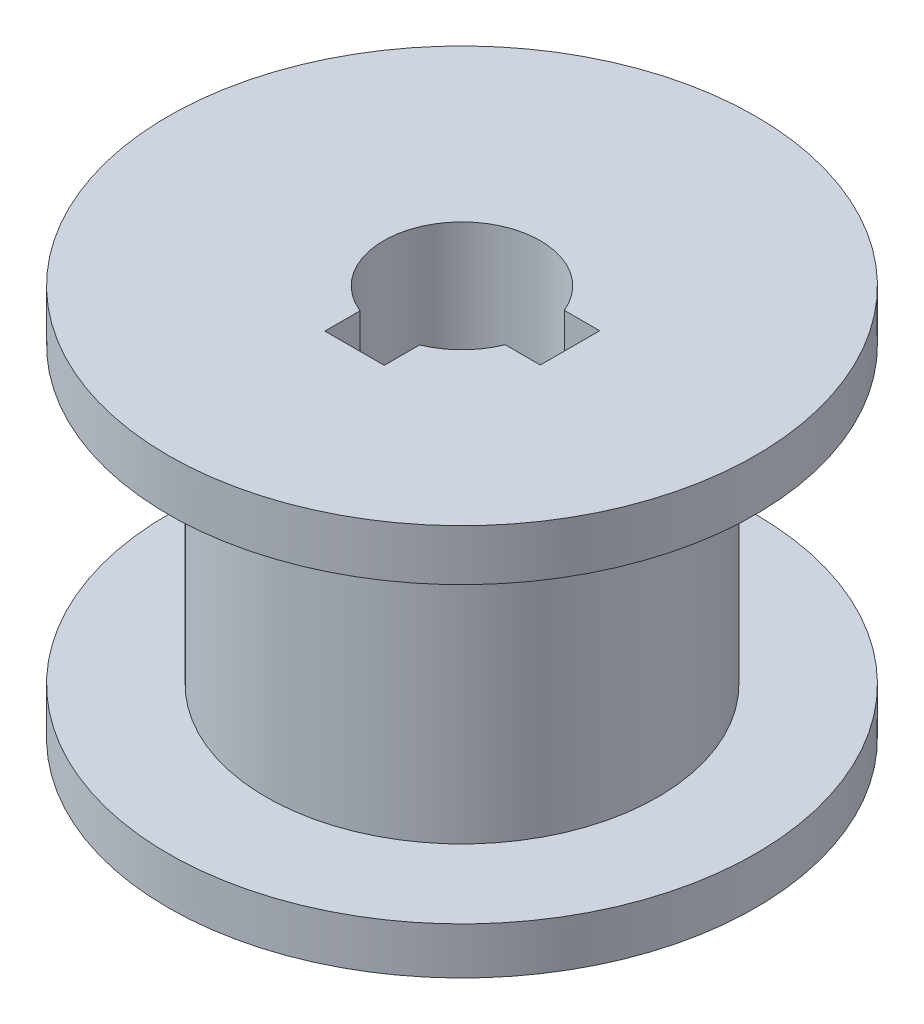
from build123d import *

# Parameters (mm, degrees)
SKETCH_1_R      = 15
EXTRUDE_1_DEPTH = 20
SKETCH_2_W      = 5
SKETCH_2_H      = 15


with BuildPart() as part:
    # 草图1 → 凸台-拉伸1 (new body)
    with BuildSketch(Plane(origin=(0, 0, 0), x_dir=(1, 0, 0), z_dir=(0, 1, 0))):
        Circle(SKETCH_1_R)
        with BuildLine():
            Line((1.53, -5.5), (0, -5.5))
            Line((0, -5.5), (-1.5, -5.5))
            Line((-1.5, -5.5), (-1.5, -3.708099244))
            ThreePointArc((-1.5, -3.708099244), (-2.839864336, 2.816943477), (3.695821965, 1.53))
            Line((3.695821965, 1.53), (5.5, 1.53))
            Line((5.5, 1.53), (5.5, 0))
            Line((5.5, 0), (5.5, -1.5))
            Line((5.5, -1.5), (3.708099244, -1.5))
            ThreePointArc((3.708099244, -1.5), (2.839864336, -2.816943477), (1.53, -3.695821965))
            Line((1.53, -3.695821965), (1.53, -5.5))
        make_face(mode=Mode.SUBTRACT)
    extrude(amount=EXTRUDE_1_DEPTH)

    # 草图2 → 切除-旋转1 (revolve, cut)
    with BuildSketch(Plane.XY):
        with Locations((12.5, 9.892021361)):
            Rectangle(SKETCH_2_W, SKETCH_2_H)
    revolve(axis=Axis((0, 0, 0), (0, 1, 0)), mode=Mode.SUBTRACT)


solid = part.part
